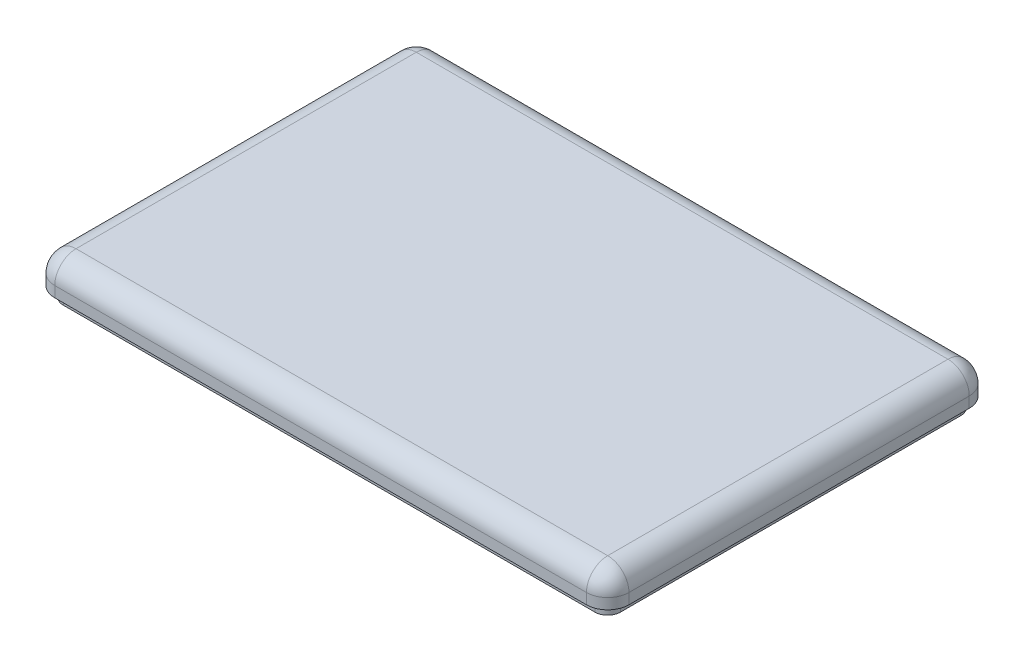
from build123d import *

# Parameters (mm, degrees)
SKETCH1_W      = 270
SKETCH1_H      = 180
EXTRUDE1_DEPTH = 20
FILLET1_R      = 10
EXTRUDE3_DEPTH = 5


with BuildPart() as part:
    # Sketch1 → Extrude1 (new body)
    with BuildSketch(Plane(origin=(0, 0, 0), x_dir=(1, 0, 0), z_dir=(0, 1, 0))):
        Rectangle(SKETCH1_W, SKETCH1_H)
    extrude(amount=EXTRUDE1_DEPTH)

    # Fillet1
    fillet1_edges = [part.edges().sort_by_distance(p)[0] for p in [
        (-135, 20, 0),
        (0, 20, 90),
        (135, 20, 0),
        (0, 20, -90),
        (135, 10, 90),
        (-135, 10, 90),
        (-135, 10, -90),
        (135, 10, -90),
    ]]
    fillet(fillet1_edges, radius=FILLET1_R)

    # Sketch3 → Extrude3 (cut)
    with BuildSketch(Plane.XZ):
        with BuildLine():
            Line((125, 90), (-125, 90))
            ThreePointArc((-125, 90), (-132.071067812, 87.071067812), (-135, 80))
            Line((-135, 80), (-135, -80))
            ThreePointArc((-135, -80), (-132.071067812, -87.071067812), (-125, -90))
            Line((-125, -90), (125, -90))
            ThreePointArc((125, -90), (132.071067812, -87.071067812), (135, -80))
            Line((135, -80), (135, 80))
            ThreePointArc((135, 80), (132.071067812, 87.071067812), (125, 90))
        make_face()
        with BuildLine():
            Line((-131, 80), (-131, -80))
            ThreePointArc((-131, -80), (-129.242640687, -84.242640687), (-125, -86))
            Line((-125, -86), (125, -86))
            ThreePointArc((125, -86), (129.242640687, -84.242640687), (131, -80))
            Line((131, -80), (131, 80))
            ThreePointArc((131, 80), (129.242640687, 84.242640687), (125, 86))
            Line((125, 86), (-125, 86))
            ThreePointArc((-125, 86), (-129.242640687, 84.242640687), (-131, 80))
        make_face(mode=Mode.SUBTRACT)
    extrude(amount=-EXTRUDE3_DEPTH, mode=Mode.SUBTRACT)


solid = part.part
